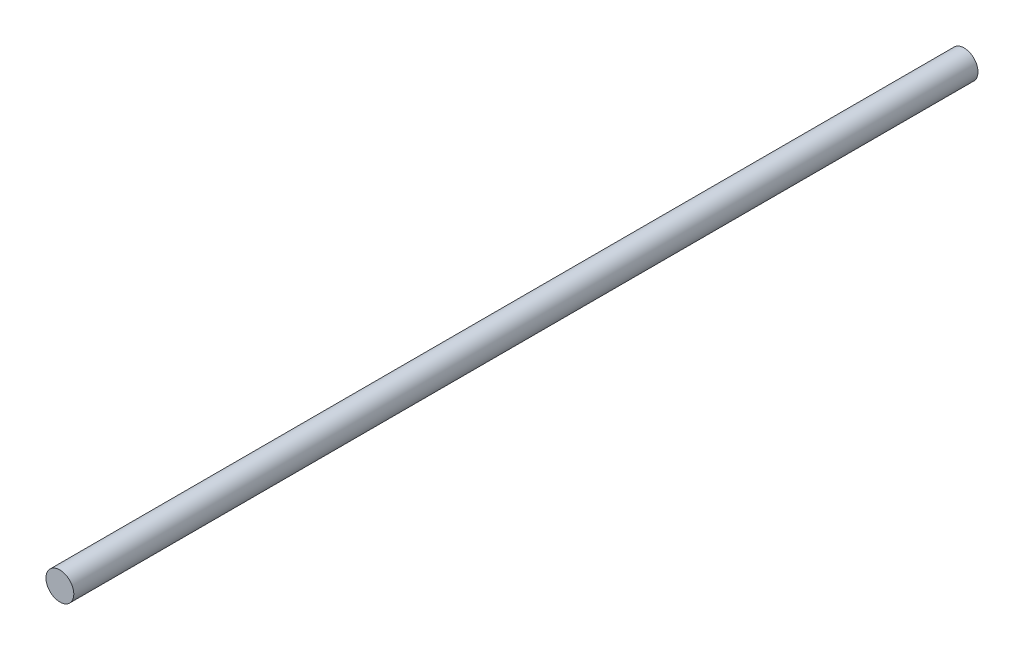
from build123d import *

# Parameters (mm, degrees)
SKETCH1_R           = 5
BOSS_EXTRUDE1_DEPTH = 325


with BuildPart() as part:
    # Sketch1 → Boss-Extrude1 (new body)
    with BuildSketch(Plane.XY):
        Circle(SKETCH1_R)
    extrude(amount=BOSS_EXTRUDE1_DEPTH)


solid = part.part
